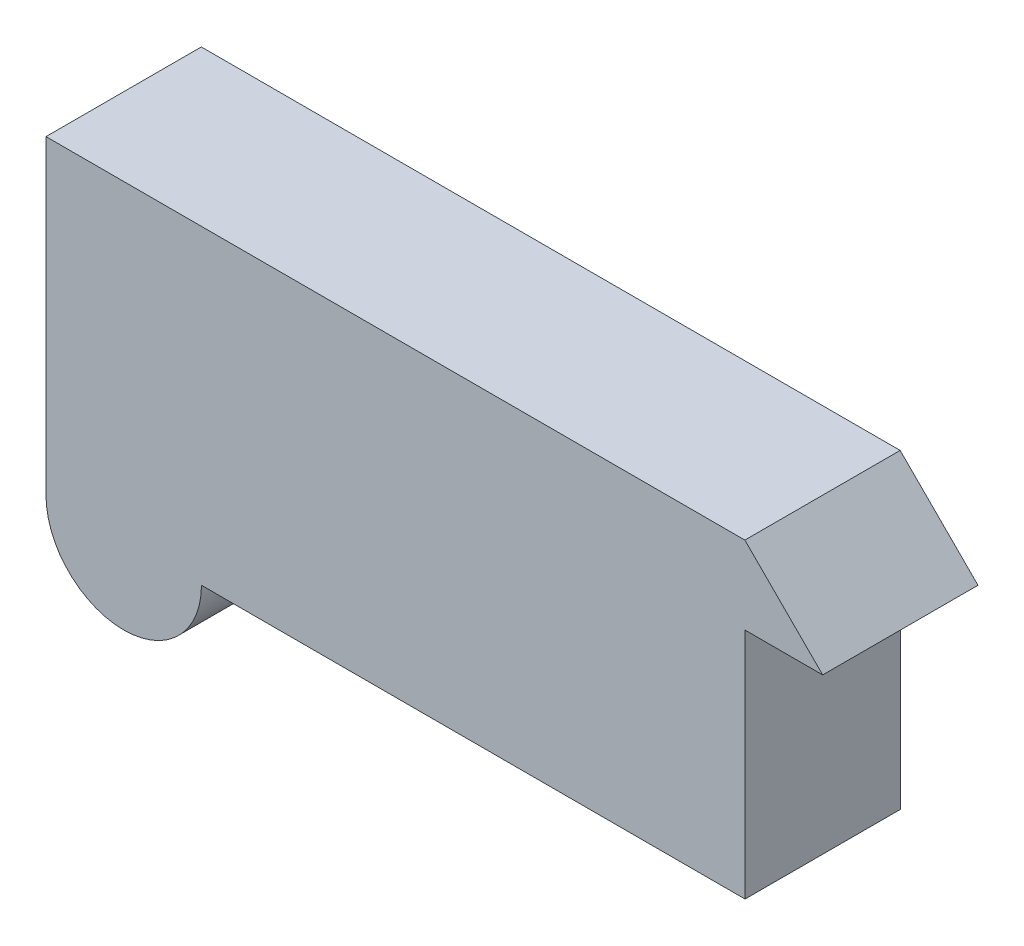
from build123d import *

# Parameters (mm, degrees)
BOSS_EXTRUDE1_DEPTH = 508


with BuildPart() as part:
    # Sketch1 → Boss-Extrude1 (new body)
    with BuildSketch(Plane.XY):
        with BuildLine():
            Line((-1664.53924545, 1529.861538462), (621.46075455, 1529.861538462))
            Line((621.46075455, 1529.861538462), (876.093987038, 1275.228305974))
            Line((876.093987038, 1275.228305974), (622.093987038, 1275.228305974))
            Line((622.093987038, 1275.228305974), (622.093987038, 513.228305974))
            Line((622.093987038, 513.228305974), (-1155.906012962, 513.228305974))
            ThreePointArc((-1155.906012962, 513.228305974), (-1410.53924545, 259.228305974), (-1664.53924545, 513.861538462))
            Line((-1664.53924545, 513.861538462), (-1664.53924545, 1529.861538462))
        make_face()
    extrude(amount=BOSS_EXTRUDE1_DEPTH)


solid = part.part
